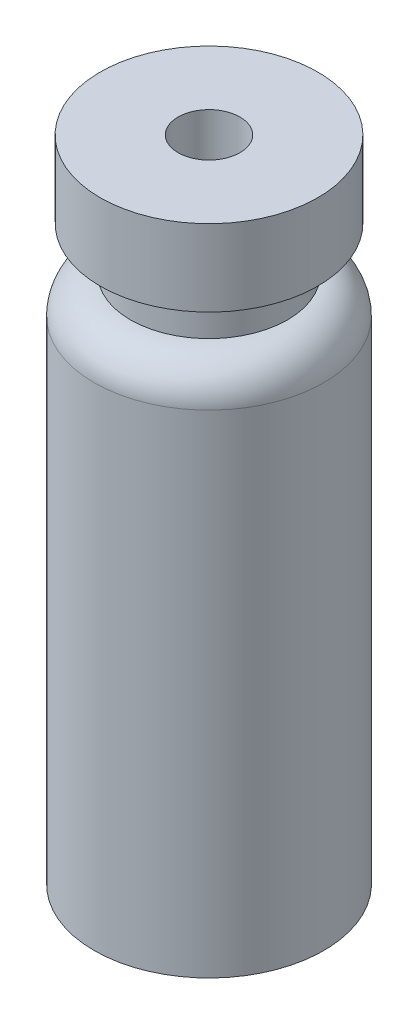
from build123d import *


with BuildPart() as part:
    # Sketch2 → Revolve1 (revolve)
    with BuildSketch(Plane.XY):
        with BuildLine():
            Line((0, 0), (5.7, 0))
            Line((5.7, 0), (5.7, 24.4))
            ThreePointArc((5.7, 24.4), (5.172792206, 25.672792206), (3.9, 26.2))
            Line((3.9, 26.2), (3.9, 28.4))
            Line((3.9, 28.4), (5.4, 28.4))
            Line((5.4, 28.4), (5.4, 32.2))
            Line((5.4, 32.2), (1.535, 32.2))
            Line((1.535, 32.2), (1.535, 9.834154564))
            Line((1.535, 9.834154564), (0.493536823, 3.419866334))
            ThreePointArc((0.493536823, 3.419866334), (0.323985468, 3.119167469), (0, 3))
            Line((0, 3), (0, 0))
        make_face()
    revolve(axis=Axis((0, 32.2, 0), (0, -1, 0)))


solid = part.part
